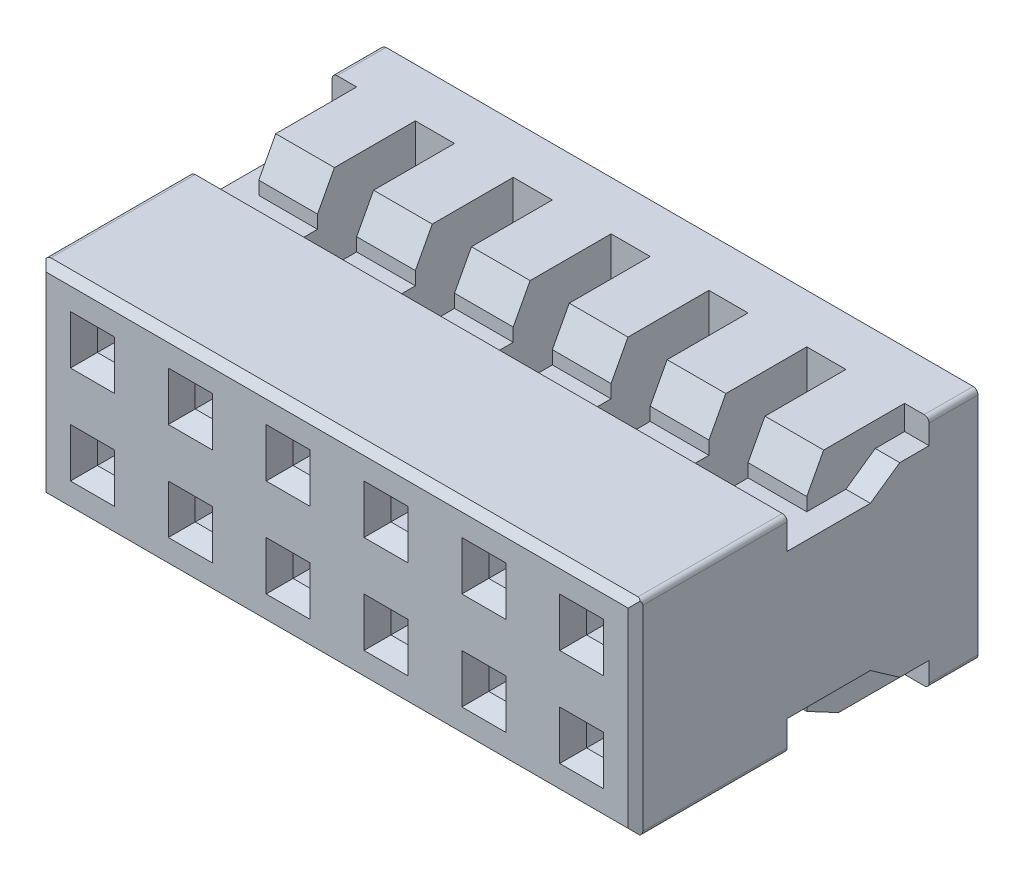
from build123d import *

# Parameters (mm, degrees)
SKETCH130_W                   = 7
SKETCH130_H                   = 4.8
EXTRUDE21_DEPTH               = 12.2
CUT_EXTRUDE110_DEPTH          = 0.5
CUT_EXTRUDE111_DEPTH          = 0.5
CUT_EXTRUDE112_DEPTH          = 0.5
CUT_EXTRUDE113_DEPTH          = 0.5
SKETCH135_W                   = 0.8
SKETCH135_H                   = 2.9
CUT_EXTRUDE114_DEPTH          = 4.8
SKETCH136_W                   = 0.8
SKETCH136_H                   = 2.9
CUT_EXTRUDE115_DEPTH          = 4.8
SKETCH137_W                   = 0.8
SKETCH137_H                   = 2.9
CUT_EXTRUDE116_DEPTH          = 4.8
SKETCH138_W                   = 0.8
SKETCH138_H                   = 2.9
CUT_EXTRUDE117_DEPTH          = 4.8
SKETCH139_W                   = 0.8
SKETCH139_H                   = 2.9
CUT_EXTRUDE118_DEPTH          = 4.8
SKETCH140_W                   = 1.2
SKETCH140_H                   = 0.920124523
CUT_EXTRUDE119_DEPTH          = 0.9
SKETCH141_W                   = 1.2
SKETCH141_H                   = 0.920124523
CUT_EXTRUDE120_DEPTH          = 0.9
SKETCH142_W                   = 1.2
SKETCH142_H                   = 0.920124523
CUT_EXTRUDE121_DEPTH          = 0.9
SKETCH143_W                   = 1.2
SKETCH143_H                   = 0.920124523
CUT_EXTRUDE122_DEPTH          = 0.9
SKETCH144_W                   = 0.8
SKETCH144_H                   = 2.959750954
CUT_EXTRUDE123_DEPTH          = 2.85
SKETCH145_W                   = 0.8
SKETCH145_H                   = 2.959750954
CUT_EXTRUDE124_DEPTH          = 2.85
SKETCH146_W                   = 0.8
SKETCH146_H                   = 2.959750954
CUT_EXTRUDE125_DEPTH          = 2.85
SKETCH147_W                   = 0.8
SKETCH147_H                   = 2.959750954
CUT_EXTRUDE126_DEPTH          = 2.85
SKETCH148_W                   = 0.8
SKETCH148_H                   = 2.959750954
CUT_EXTRUDE127_DEPTH          = 2.85
CUT_EXTRUDE128_DEPTH          = 0.3
CUT_EXTRUDE129_DEPTH          = 0.3
SKETCH151_W                   = 0.8
SKETCH151_H                   = 0.920124523
CUT_EXTRUDE130_DEPTH          = 1
SKETCH152_W                   = 0.8
SKETCH152_H                   = 0.920124523
CUT_EXTRUDE131_DEPTH          = 1
SKETCH153_W                   = 0.8
SKETCH153_H                   = 0.920124523
CUT_EXTRUDE132_DEPTH          = 1
SKETCH154_W                   = 0.8
SKETCH154_H                   = 0.920124523
CUT_EXTRUDE133_DEPTH          = 1
SKETCH155_W                   = 0.8
SKETCH155_H                   = 0.920124523
CUT_EXTRUDE134_DEPTH          = 1
SKETCH156_W                   = 0.8
SKETCH156_H                   = 1.840249046
EXTRUDE22_DEPTH               = 1.2
SKETCH157_W                   = 0.8
SKETCH157_H                   = 1.840249046
EXTRUDE23_DEPTH               = 1.2
SKETCH158_W                   = 0.8
SKETCH158_H                   = 1.840249046
EXTRUDE24_DEPTH               = 1.2
SKETCH159_W                   = 0.8
SKETCH159_H                   = 1.840249046
EXTRUDE25_DEPTH               = 1.2
SKETCH160_W                   = 0.8
SKETCH160_H                   = 1.840249046
EXTRUDE26_DEPTH               = 1.2
SKETCH161_W                   = 0.8
SKETCH161_H                   = 0.199377385
CUT_EXTRUDE135_DEPTH          = 1
LPATTERN13_COUNT              = 5
LPATTERN13_PITCH              = 2
SKETCH162_W                   = 1.2
SKETCH162_H                   = 0.9
CUT_EXTRUDE136_DEPTH          = 0.620124523
SKETCH163_W                   = 1.2
SKETCH163_H                   = 0.9
CUT_EXTRUDE137_DEPTH          = 0.620124523
SKETCH164_W                   = 1.2
SKETCH164_H                   = 0.9
CUT_EXTRUDE138_DEPTH          = 0.620124523
SKETCH165_W                   = 1.2
SKETCH165_H                   = 0.9
CUT_EXTRUDE139_DEPTH          = 0.620124523
SKETCH166_W                   = 1.2
SKETCH166_H                   = 0.9
CUT_EXTRUDE140_DEPTH          = 0.620124523
SKETCH167_W                   = 1.2
SKETCH167_H                   = 0.9
CUT_EXTRUDE141_DEPTH          = 0.620124523
SKETCH168_W                   = 1.2
SKETCH168_H                   = 0.9
CUT_EXTRUDE142_DEPTH          = 0.620124523
SKETCH169_W                   = 1.2
SKETCH169_H                   = 0.9
CUT_EXTRUDE143_DEPTH          = 0.620124523
CHAMFER85_SIZE                = 0.420124523
CHAMFER85_SIZE2               = 0.6
CHAMFER86_SIZE                = 0.420124523
CHAMFER86_SIZE2               = 0.6
CHAMFER87_SIZE                = 0.420124523
CHAMFER87_SIZE2               = 0.6
CHAMFER88_SIZE                = 0.420124523
CHAMFER88_SIZE2               = 0.6
CHAMFER89_SIZE                = 0.420124523
CHAMFER89_SIZE2               = 0.6
CHAMFER90_SIZE                = 0.6
CHAMFER90_SIZE2               = 0.420124523
CHAMFER91_SIZE                = 0.6
CHAMFER91_SIZE2               = 0.420124523
CHAMFER92_SIZE                = 0.6
CHAMFER92_SIZE2               = 0.420124523
CHAMFER93_SIZE                = 0.6
CHAMFER93_SIZE2               = 0.420124523
CHAMFER94_SIZE                = 0.6
CHAMFER94_SIZE2               = 0.420124523
CHAMFER95_SIZE                = 0.345611131
CHAMFER95_SIZE2               = 0.65
CHAMFER95_PART_2_SIZE         = 0.345611131
CHAMFER95_PART_2_SIZE2        = 0.65
CHAMFER95_PART_3_SIZE         = 0.345611131
CHAMFER95_PART_3_SIZE2        = 0.65
CHAMFER95_PART_4_SIZE         = 0.345611131
CHAMFER95_PART_4_SIZE2        = 0.65
CHAMFER95_PART_5_SIZE         = 0.345611131
CHAMFER95_PART_5_SIZE2        = 0.65
CHAMFER95_PART_6_SIZE         = 0.345611131
CHAMFER95_PART_6_SIZE2        = 0.65
CHAMFER96_SIZE                = 0.65
CHAMFER96_SIZE2               = 0.345611131
CHAMFER96_PART_2_SIZE         = 0.65
CHAMFER96_PART_2_SIZE2        = 0.345611131
CHAMFER96_PART_3_SIZE         = 0.65
CHAMFER96_PART_3_SIZE2        = 0.345611131
CHAMFER96_PART_4_SIZE         = 0.65
CHAMFER96_PART_4_SIZE2        = 0.345611131
CHAMFER96_PART_5_SIZE         = 0.65
CHAMFER96_PART_5_SIZE2        = 0.345611131
CHAMFER96_PART_6_SIZE         = 0.65
CHAMFER96_PART_6_SIZE2        = 0.345611131
SKETCH170_W                   = 0.5
SKETCH170_H                   = 0.6
CUT_EXTRUDE144_DEPTH          = 7
CHAMFER97_SIZE                = 0.2
CHAMFER97_SIZE2               = 0.35
CHAMFER98_SIZE                = 0.15
FILLET13_R                    = 0.1
FILLET14_R                    = 0.1
LPATTERN14_COUNT              = 6
LPATTERN14_PITCH              = 2
LPATTERN14_COUNT_DIR2         = 2
LPATTERN14_PITCH_DIR2         = 2
CHAMFER97_OF_LPATTERN14_SIZE2 = 0.35
CHAMFER97_OF_LPATTERN14_SIZE  = 0.2


with BuildPart() as part:
    # Sketch130 → Extrude21 (new body)
    with BuildSketch(Plane(origin=(6.1, 0, 0), x_dir=(0, 0, -1), z_dir=(1, 0, 0))):
        with Locations((3.5, 0)):
            Rectangle(SKETCH130_W, SKETCH130_H)
    extrude(amount=-EXTRUDE21_DEPTH)

    # Sketch131 → Cut-Extrude110 (cut)
    with BuildSketch(Plane(origin=(6.1, 0, 0), x_dir=(0, 0, -1), z_dir=(1, 0, 0))):
        Polygon((4.8, -1.479875477), (3.1, -1.479875477), (3.1, -2.4), (6, -2.4), (6, -1.9), (5.4, -1.9), align=None)
    extrude(amount=-CUT_EXTRUDE110_DEPTH, mode=Mode.SUBTRACT)

    # Sketch132 → Cut-Extrude111 (cut)
    with BuildSketch(Plane(origin=(6.1, 0, 0), x_dir=(0, 0, -1), z_dir=(1, 0, 0))):
        Polygon((6, 2.4), (3.1, 2.4), (3.1, 1.479875477), (4.8, 1.479875477), (5.4, 1.9), (6, 1.9), align=None)
    extrude(amount=-CUT_EXTRUDE111_DEPTH, mode=Mode.SUBTRACT)

    # Sketch133 → Cut-Extrude112 (cut)
    with BuildSketch(Plane.ZY.offset(6.1)):
        Polygon((-4.8, 1.479875477), (-3.1, 1.479875477), (-3.1, 2.4), (-6, 2.4), (-6, 1.9), (-5.4, 1.9), align=None)
    extrude(amount=-CUT_EXTRUDE112_DEPTH, mode=Mode.SUBTRACT)

    # Sketch134 → Cut-Extrude113 (cut)
    with BuildSketch(Plane.ZY.offset(6.1)):
        Polygon((-6, -2.4), (-3.1, -2.4), (-3.1, -1.479875477), (-4.8, -1.479875477), (-5.4, -1.9), (-6, -1.9), align=None)
    extrude(amount=-CUT_EXTRUDE113_DEPTH, mode=Mode.SUBTRACT)

    # Sketch135 → Cut-Extrude114 (cut)
    with BuildSketch(Plane(origin=(0, 2.4, 0), x_dir=(-1, 0, 0), z_dir=(0, 1, 0))):
        with Locations((-4, -4.55)):
            Rectangle(SKETCH135_W, SKETCH135_H)
    extrude(amount=-CUT_EXTRUDE114_DEPTH, mode=Mode.SUBTRACT)

    # Sketch136 → Cut-Extrude115 (cut)
    with BuildSketch(Plane(origin=(0, 2.4, 0), x_dir=(-1, 0, 0), z_dir=(0, 1, 0))):
        with Locations((-2, -4.55)):
            Rectangle(SKETCH136_W, SKETCH136_H)
    extrude(amount=-CUT_EXTRUDE115_DEPTH, mode=Mode.SUBTRACT)

    # Sketch137 → Cut-Extrude116 (cut)
    with BuildSketch(Plane(origin=(0, 2.4, 0), x_dir=(-1, 0, 0), z_dir=(0, 1, 0))):
        with Locations((0, -4.55)):
            Rectangle(SKETCH137_W, SKETCH137_H)
    extrude(amount=-CUT_EXTRUDE116_DEPTH, mode=Mode.SUBTRACT)

    # Sketch138 → Cut-Extrude117 (cut)
    with BuildSketch(Plane(origin=(0, 2.4, 0), x_dir=(-1, 0, 0), z_dir=(0, 1, 0))):
        with Locations((2, -4.55)):
            Rectangle(SKETCH138_W, SKETCH138_H)
    extrude(amount=-CUT_EXTRUDE117_DEPTH, mode=Mode.SUBTRACT)

    # Sketch139 → Cut-Extrude118 (cut)
    with BuildSketch(Plane(origin=(0, 2.4, 0), x_dir=(-1, 0, 0), z_dir=(0, 1, 0))):
        with Locations((4, -4.55)):
            Rectangle(SKETCH139_W, SKETCH139_H)
    extrude(amount=-CUT_EXTRUDE118_DEPTH, mode=Mode.SUBTRACT)

    # Sketch140 → Cut-Extrude119 (cut)
    with BuildSketch(Plane.XY.offset(-3.1)):
        with Locations((5, -1.939937739)):
            Rectangle(SKETCH140_W, SKETCH140_H)
    extrude(amount=-CUT_EXTRUDE119_DEPTH, mode=Mode.SUBTRACT)

    # Sketch141 → Cut-Extrude120 (cut)
    with BuildSketch(Plane.XY.offset(-3.1)):
        with Locations((-5, -1.939937739)):
            Rectangle(SKETCH141_W, SKETCH141_H)
    extrude(amount=-CUT_EXTRUDE120_DEPTH, mode=Mode.SUBTRACT)

    # Sketch142 → Cut-Extrude121 (cut)
    with BuildSketch(Plane.XY.offset(-3.1)):
        with Locations((5, 1.939937739)):
            Rectangle(SKETCH142_W, SKETCH142_H)
    extrude(amount=-CUT_EXTRUDE121_DEPTH, mode=Mode.SUBTRACT)

    # Sketch143 → Cut-Extrude122 (cut)
    with BuildSketch(Plane.XY.offset(-3.1)):
        with Locations((-5, 1.939937739)):
            Rectangle(SKETCH143_W, SKETCH143_H)
    extrude(amount=-CUT_EXTRUDE122_DEPTH, mode=Mode.SUBTRACT)

    # Sketch144 → Cut-Extrude123 (cut)
    with BuildSketch(Plane(origin=(0, 0, -3.1), x_dir=(-1, 0, 0), z_dir=(0, 0, -1))):
        with Locations((-4, 0)):
            Rectangle(SKETCH144_W, SKETCH144_H)
    extrude(amount=-CUT_EXTRUDE123_DEPTH, mode=Mode.SUBTRACT)

    # Sketch145 → Cut-Extrude124 (cut)
    with BuildSketch(Plane(origin=(0, 0, -3.1), x_dir=(-1, 0, 0), z_dir=(0, 0, -1))):
        with Locations((-2, 0)):
            Rectangle(SKETCH145_W, SKETCH145_H)
    extrude(amount=-CUT_EXTRUDE124_DEPTH, mode=Mode.SUBTRACT)

    # Sketch146 → Cut-Extrude125 (cut)
    with BuildSketch(Plane(origin=(0, 0, -3.1), x_dir=(-1, 0, 0), z_dir=(0, 0, -1))):
        Rectangle(SKETCH146_W, SKETCH146_H)
    extrude(amount=-CUT_EXTRUDE125_DEPTH, mode=Mode.SUBTRACT)

    # Sketch147 → Cut-Extrude126 (cut)
    with BuildSketch(Plane(origin=(0, 0, -3.1), x_dir=(-1, 0, 0), z_dir=(0, 0, -1))):
        with Locations((2, 0)):
            Rectangle(SKETCH147_W, SKETCH147_H)
    extrude(amount=-CUT_EXTRUDE126_DEPTH, mode=Mode.SUBTRACT)

    # Sketch148 → Cut-Extrude127 (cut)
    with BuildSketch(Plane(origin=(0, 0, -3.1), x_dir=(-1, 0, 0), z_dir=(0, 0, -1))):
        with Locations((4, 0)):
            Rectangle(SKETCH148_W, SKETCH148_H)
    extrude(amount=-CUT_EXTRUDE127_DEPTH, mode=Mode.SUBTRACT)

    # Sketch149 → Cut-Extrude128 (cut)
    with BuildSketch(Plane.XZ.offset(2.4)):
        Polygon((6.1, -3.1), (6.1, 0), (-6.1, 0), (-6.1, -3.1), (-3.6, -3.1), (-3.6, -4), (-2.4, -4), (-2.4, -3.1), (-1.6, -3.1), (-1.6, -4), (-0.4, -4), (-0.4, -3.1), (0.4, -3.1), (0.4, -4), (1.6, -4), (1.6, -3.1), (2.4, -3.1), (2.4, -4), (3.6, -4), (3.6, -3.1), align=None)
    extrude(amount=-CUT_EXTRUDE128_DEPTH, mode=Mode.SUBTRACT)

    # Sketch150 → Cut-Extrude129 (cut)
    with BuildSketch(Plane(origin=(0, 2.4, 0), x_dir=(-1, 0, 0), z_dir=(0, 1, 0))):
        Polygon((3.6, -3.1), (6.1, -3.1), (6.1, 0), (-6.1, 0), (-6.1, -3.1), (-3.6, -3.1), (-3.6, -4), (-2.4, -4), (-2.4, -3.1), (-1.6, -3.1), (-1.6, -4), (-0.4, -4), (-0.4, -3.1), (0.4, -3.1), (0.4, -4), (1.6, -4), (1.6, -3.1), (2.4, -3.1), (2.4, -4), (3.6, -4), align=None)
    extrude(amount=-CUT_EXTRUDE129_DEPTH, mode=Mode.SUBTRACT)

    # Sketch151 → Cut-Extrude130 (cut)
    with BuildSketch(Plane.XY.offset(-6)):
        with Locations((-4, 1.019813216)):
            Rectangle(SKETCH151_W, SKETCH151_H)
    extrude(amount=-CUT_EXTRUDE130_DEPTH, mode=Mode.SUBTRACT)

    # Sketch152 → Cut-Extrude131 (cut)
    with BuildSketch(Plane.XY.offset(-6)):
        with Locations((-2, 1.019813216)):
            Rectangle(SKETCH152_W, SKETCH152_H)
    extrude(amount=-CUT_EXTRUDE131_DEPTH, mode=Mode.SUBTRACT)

    # Sketch153 → Cut-Extrude132 (cut)
    with BuildSketch(Plane.XY.offset(-6)):
        with Locations((0, 1.019813216)):
            Rectangle(SKETCH153_W, SKETCH153_H)
    extrude(amount=-CUT_EXTRUDE132_DEPTH, mode=Mode.SUBTRACT)

    # Sketch154 → Cut-Extrude133 (cut)
    with BuildSketch(Plane.XY.offset(-6)):
        with Locations((2, 1.019813216)):
            Rectangle(SKETCH154_W, SKETCH154_H)
    extrude(amount=-CUT_EXTRUDE133_DEPTH, mode=Mode.SUBTRACT)

    # Sketch155 → Cut-Extrude134 (cut)
    with BuildSketch(Plane.XY.offset(-6)):
        with Locations((4, 1.019813216)):
            Rectangle(SKETCH155_W, SKETCH155_H)
    extrude(amount=-CUT_EXTRUDE134_DEPTH, mode=Mode.SUBTRACT)

    # Sketch156 → Extrude22 (add)
    with BuildSketch(Plane.XY.offset(-6)):
        with Locations((-4, -0.360373569)):
            Rectangle(SKETCH156_W, SKETCH156_H)
    extrude(amount=EXTRUDE22_DEPTH)

    # Sketch157 → Extrude23 (add)
    with BuildSketch(Plane.XY.offset(-6)):
        with Locations((-2, -0.360373569)):
            Rectangle(SKETCH157_W, SKETCH157_H)
    extrude(amount=EXTRUDE23_DEPTH)

    # Sketch158 → Extrude24 (add)
    with BuildSketch(Plane.XY.offset(-6)):
        with Locations((0, -0.360373569)):
            Rectangle(SKETCH158_W, SKETCH158_H)
    extrude(amount=EXTRUDE24_DEPTH)

    # Sketch159 → Extrude25 (add)
    with BuildSketch(Plane.XY.offset(-6)):
        with Locations((2, -0.360373569)):
            Rectangle(SKETCH159_W, SKETCH159_H)
    extrude(amount=EXTRUDE25_DEPTH)

    # Sketch160 → Extrude26 (add)
    with BuildSketch(Plane.XY.offset(-6)):
        with Locations((4, -0.360373569)):
            Rectangle(SKETCH160_W, SKETCH160_H)
    extrude(amount=EXTRUDE26_DEPTH)

    # Sketch161 → Cut-Extrude135 (cut)
    with BuildSketch(Plane.XY.offset(-6)):
        with Locations((-4, -1.380186784)):
            Rectangle(SKETCH161_W, SKETCH161_H)
    cut_extrude135 = extrude(amount=-CUT_EXTRUDE135_DEPTH, mode=Mode.SUBTRACT)

    # LPattern13: Cut-Extrude135 ×5
    with Locations(*[(i * LPATTERN13_PITCH, 0, 0) for i in range(1, LPATTERN13_COUNT)]):
        add(cut_extrude135, mode=Mode.SUBTRACT)

    # Sketch162 → Cut-Extrude136 (cut)
    with BuildSketch(Plane.XZ.offset(2.1)):
        with Locations((-3, -3.55)):
            Rectangle(SKETCH162_W, SKETCH162_H)
    extrude(amount=-CUT_EXTRUDE136_DEPTH, mode=Mode.SUBTRACT)

    # Sketch163 → Cut-Extrude137 (cut)
    with BuildSketch(Plane.XZ.offset(2.1)):
        with Locations((-1, -3.55)):
            Rectangle(SKETCH163_W, SKETCH163_H)
    extrude(amount=-CUT_EXTRUDE137_DEPTH, mode=Mode.SUBTRACT)

    # Sketch164 → Cut-Extrude138 (cut)
    with BuildSketch(Plane.XZ.offset(2.1)):
        with Locations((1, -3.55)):
            Rectangle(SKETCH164_W, SKETCH164_H)
    extrude(amount=-CUT_EXTRUDE138_DEPTH, mode=Mode.SUBTRACT)

    # Sketch165 → Cut-Extrude139 (cut)
    with BuildSketch(Plane.XZ.offset(2.1)):
        with Locations((3, -3.55)):
            Rectangle(SKETCH165_W, SKETCH165_H)
    extrude(amount=-CUT_EXTRUDE139_DEPTH, mode=Mode.SUBTRACT)

    # Sketch166 → Cut-Extrude140 (cut)
    with BuildSketch(Plane(origin=(0, 2.1, 0), x_dir=(-1, 0, 0), z_dir=(0, 1, 0))):
        with Locations((-3, -3.55)):
            Rectangle(SKETCH166_W, SKETCH166_H)
    extrude(amount=-CUT_EXTRUDE140_DEPTH, mode=Mode.SUBTRACT)

    # Sketch167 → Cut-Extrude141 (cut)
    with BuildSketch(Plane(origin=(0, 2.1, 0), x_dir=(-1, 0, 0), z_dir=(0, 1, 0))):
        with Locations((-1, -3.55)):
            Rectangle(SKETCH167_W, SKETCH167_H)
    extrude(amount=-CUT_EXTRUDE141_DEPTH, mode=Mode.SUBTRACT)

    # Sketch168 → Cut-Extrude142 (cut)
    with BuildSketch(Plane(origin=(0, 2.1, 0), x_dir=(-1, 0, 0), z_dir=(0, 1, 0))):
        with Locations((1, -3.55)):
            Rectangle(SKETCH168_W, SKETCH168_H)
    extrude(amount=-CUT_EXTRUDE142_DEPTH, mode=Mode.SUBTRACT)

    # Sketch169 → Cut-Extrude143 (cut)
    with BuildSketch(Plane(origin=(0, 2.1, 0), x_dir=(-1, 0, 0), z_dir=(0, 1, 0))):
        with Locations((3, -3.55)):
            Rectangle(SKETCH169_W, SKETCH169_H)
    extrude(amount=-CUT_EXTRUDE143_DEPTH, mode=Mode.SUBTRACT)

    # Chamfer85
    chamfer85_edges = [part.edges().sort_by_distance(p)[0] for p in [
        (4, -1.280498092, -4.8),
    ]]
    chamfer85_side = [part.faces().sort_by_distance(p)[0] for p in [
        (4, -1.280498092, -5.9),
    ]]
    chamfer(chamfer85_edges, length=CHAMFER85_SIZE, length2=CHAMFER85_SIZE2, reference=chamfer85_side[0])

    # Chamfer86
    chamfer86_edges = [part.edges().sort_by_distance(p)[0] for p in [
        (2, -1.280498092, -4.8),
    ]]
    chamfer86_side = [part.faces().sort_by_distance(p)[0] for p in [
        (2, -1.280498092, -5.9),
    ]]
    chamfer(chamfer86_edges, length=CHAMFER86_SIZE, length2=CHAMFER86_SIZE2, reference=chamfer86_side[0])

    # Chamfer87
    chamfer87_edges = [part.edges().sort_by_distance(p)[0] for p in [
        (0, -1.280498092, -4.8),
    ]]
    chamfer87_side = [part.faces().sort_by_distance(p)[0] for p in [
        (0, -1.280498092, -5.9),
    ]]
    chamfer(chamfer87_edges, length=CHAMFER87_SIZE, length2=CHAMFER87_SIZE2, reference=chamfer87_side[0])

    # Chamfer88
    chamfer88_edges = [part.edges().sort_by_distance(p)[0] for p in [
        (-2, -1.280498092, -4.8),
    ]]
    chamfer88_side = [part.faces().sort_by_distance(p)[0] for p in [
        (-2, -1.280498092, -5.9),
    ]]
    chamfer(chamfer88_edges, length=CHAMFER88_SIZE, length2=CHAMFER88_SIZE2, reference=chamfer88_side[0])

    # Chamfer89
    chamfer89_edges = [part.edges().sort_by_distance(p)[0] for p in [
        (-4, -1.280498092, -4.8),
    ]]
    chamfer89_side = [part.faces().sort_by_distance(p)[0] for p in [
        (-4, -1.280498092, -5.9),
    ]]
    chamfer(chamfer89_edges, length=CHAMFER89_SIZE, length2=CHAMFER89_SIZE2, reference=chamfer89_side[0])

    # Chamfer90
    chamfer90_edges = [part.edges().sort_by_distance(p)[0] for p in [
        (4, 0.559750954, -4.8),
    ]]
    chamfer90_side = [part.faces().sort_by_distance(p)[0] for p in [
        (4, 0.559750954, -5.9),
    ]]
    chamfer(chamfer90_edges, length=CHAMFER90_SIZE, length2=CHAMFER90_SIZE2, reference=chamfer90_side[0])

    # Chamfer91
    chamfer91_edges = [part.edges().sort_by_distance(p)[0] for p in [
        (2, 0.559750954, -4.8),
    ]]
    chamfer91_side = [part.faces().sort_by_distance(p)[0] for p in [
        (2, 0.559750954, -5.9),
    ]]
    chamfer(chamfer91_edges, length=CHAMFER91_SIZE, length2=CHAMFER91_SIZE2, reference=chamfer91_side[0])

    # Chamfer92
    chamfer92_edges = [part.edges().sort_by_distance(p)[0] for p in [
        (0, 0.559750954, -4.8),
    ]]
    chamfer92_side = [part.faces().sort_by_distance(p)[0] for p in [
        (0, 0.559750954, -5.9),
    ]]
    chamfer(chamfer92_edges, length=CHAMFER92_SIZE, length2=CHAMFER92_SIZE2, reference=chamfer92_side[0])

    # Chamfer93
    chamfer93_edges = [part.edges().sort_by_distance(p)[0] for p in [
        (-2, 0.559750954, -4.8),
    ]]
    chamfer93_side = [part.faces().sort_by_distance(p)[0] for p in [
        (-2, 0.559750954, -5.9),
    ]]
    chamfer(chamfer93_edges, length=CHAMFER93_SIZE, length2=CHAMFER93_SIZE2, reference=chamfer93_side[0])

    # Chamfer94
    chamfer94_edges = [part.edges().sort_by_distance(p)[0] for p in [
        (-4, 0.559750954, -4.8),
    ]]
    chamfer94_side = [part.faces().sort_by_distance(p)[0] for p in [
        (-4, 0.559750954, -5.9),
    ]]
    chamfer(chamfer94_edges, length=CHAMFER94_SIZE, length2=CHAMFER94_SIZE2, reference=chamfer94_side[0])

    # Chamfer95
    chamfer95_edges = [part.edges().sort_by_distance(p)[0] for p in [
        (5, -2.4, -4),
    ]]
    chamfer95_side = [part.faces().sort_by_distance(p)[0] for p in [
        (5, -1.939937739, -4),
    ]]
    chamfer(chamfer95_edges, length=CHAMFER95_SIZE, length2=CHAMFER95_SIZE2, reference=chamfer95_side[0])

    # Chamfer95 part 2
    chamfer95_part_2_edges = [part.edges().sort_by_distance(p)[0] for p in [
        (-5, -2.4, -4),
    ]]
    chamfer95_part_2_side = [part.faces().sort_by_distance(p)[0] for p in [
        (-5, -1.939937739, -4),
    ]]
    chamfer(chamfer95_part_2_edges, length=CHAMFER95_PART_2_SIZE, length2=CHAMFER95_PART_2_SIZE2, reference=chamfer95_part_2_side[0])

    # Chamfer95 part 3
    chamfer95_part_3_edges = [part.edges().sort_by_distance(p)[0] for p in [
        (-3, -2.4, -4),
    ]]
    chamfer95_part_3_side = [part.faces().sort_by_distance(p)[0] for p in [
        (-3, -1.939937739, -4),
    ]]
    chamfer(chamfer95_part_3_edges, length=CHAMFER95_PART_3_SIZE, length2=CHAMFER95_PART_3_SIZE2, reference=chamfer95_part_3_side[0])

    # Chamfer95 part 4
    chamfer95_part_4_edges = [part.edges().sort_by_distance(p)[0] for p in [
        (-1, -2.4, -4),
    ]]
    chamfer95_part_4_side = [part.faces().sort_by_distance(p)[0] for p in [
        (-1, -1.939937739, -4),
    ]]
    chamfer(chamfer95_part_4_edges, length=CHAMFER95_PART_4_SIZE, length2=CHAMFER95_PART_4_SIZE2, reference=chamfer95_part_4_side[0])

    # Chamfer95 part 5
    chamfer95_part_5_edges = [part.edges().sort_by_distance(p)[0] for p in [
        (1, -2.4, -4),
    ]]
    chamfer95_part_5_side = [part.faces().sort_by_distance(p)[0] for p in [
        (1, -1.939937739, -4),
    ]]
    chamfer(chamfer95_part_5_edges, length=CHAMFER95_PART_5_SIZE, length2=CHAMFER95_PART_5_SIZE2, reference=chamfer95_part_5_side[0])

    # Chamfer95 part 6
    chamfer95_part_6_edges = [part.edges().sort_by_distance(p)[0] for p in [
        (3, -2.4, -4),
    ]]
    chamfer95_part_6_side = [part.faces().sort_by_distance(p)[0] for p in [
        (3, -1.939937739, -4),
    ]]
    chamfer(chamfer95_part_6_edges, length=CHAMFER95_PART_6_SIZE, length2=CHAMFER95_PART_6_SIZE2, reference=chamfer95_part_6_side[0])

    # Chamfer96
    chamfer96_edges = [part.edges().sort_by_distance(p)[0] for p in [
        (5, 2.4, -4),
    ]]
    chamfer96_side = [part.faces().sort_by_distance(p)[0] for p in [
        (5, 1.939937739, -4),
    ]]
    chamfer(chamfer96_edges, length=CHAMFER96_SIZE, length2=CHAMFER96_SIZE2, reference=chamfer96_side[0])

    # Chamfer96 part 2
    chamfer96_part_2_edges = [part.edges().sort_by_distance(p)[0] for p in [
        (-5, 2.4, -4),
    ]]
    chamfer96_part_2_side = [part.faces().sort_by_distance(p)[0] for p in [
        (-5, 1.939937739, -4),
    ]]
    chamfer(chamfer96_part_2_edges, length=CHAMFER96_PART_2_SIZE, length2=CHAMFER96_PART_2_SIZE2, reference=chamfer96_part_2_side[0])

    # Chamfer96 part 3
    chamfer96_part_3_edges = [part.edges().sort_by_distance(p)[0] for p in [
        (3, 2.4, -4),
    ]]
    chamfer96_part_3_side = [part.faces().sort_by_distance(p)[0] for p in [
        (3, 1.939937739, -4),
    ]]
    chamfer(chamfer96_part_3_edges, length=CHAMFER96_PART_3_SIZE, length2=CHAMFER96_PART_3_SIZE2, reference=chamfer96_part_3_side[0])

    # Chamfer96 part 4
    chamfer96_part_4_edges = [part.edges().sort_by_distance(p)[0] for p in [
        (1, 2.4, -4),
    ]]
    chamfer96_part_4_side = [part.faces().sort_by_distance(p)[0] for p in [
        (1, 1.939937739, -4),
    ]]
    chamfer(chamfer96_part_4_edges, length=CHAMFER96_PART_4_SIZE, length2=CHAMFER96_PART_4_SIZE2, reference=chamfer96_part_4_side[0])

    # Chamfer96 part 5
    chamfer96_part_5_edges = [part.edges().sort_by_distance(p)[0] for p in [
        (-1, 2.4, -4),
    ]]
    chamfer96_part_5_side = [part.faces().sort_by_distance(p)[0] for p in [
        (-1, 1.939937739, -4),
    ]]
    chamfer(chamfer96_part_5_edges, length=CHAMFER96_PART_5_SIZE, length2=CHAMFER96_PART_5_SIZE2, reference=chamfer96_part_5_side[0])

    # Chamfer96 part 6
    chamfer96_part_6_edges = [part.edges().sort_by_distance(p)[0] for p in [
        (-3, 2.4, -4),
    ]]
    chamfer96_part_6_side = [part.faces().sort_by_distance(p)[0] for p in [
        (-3, 1.939937739, -4),
    ]]
    chamfer(chamfer96_part_6_edges, length=CHAMFER96_PART_6_SIZE, length2=CHAMFER96_PART_6_SIZE2, reference=chamfer96_part_6_side[0])

    # Sketch170 → Cut-Extrude144 (cut)
    with BuildSketch(Plane.XY):
        with Locations((5, 1)):
            Rectangle(SKETCH170_W, SKETCH170_H)
    cut_extrude144 = extrude(amount=-CUT_EXTRUDE144_DEPTH, mode=Mode.SUBTRACT)

    # Chamfer97
    chamfer97_edges = [part.edges().sort_by_distance(p)[0] for p in [
        (4.75, 1, 0),
        (5, 0.7, 0),
        (5.25, 1, 0),
        (5, 1.3, 0),
    ]]
    chamfer97_side = [part.faces().sort_by_distance(p)[0] for p in [
        (-0.029446408, -0.005889282, 0),
    ]]
    chamfer(chamfer97_edges, length=CHAMFER97_SIZE, length2=CHAMFER97_SIZE2, reference=chamfer97_side[0])

    # Chamfer98
    chamfer98_edges = [part.edges().sort_by_distance(p)[0] for p in [
        (0, -2.1, 0),
        (6.1, 0, 0),
        (-6.1, 0, 0),
        (0, 2.1, 0),
    ]]
    chamfer(chamfer98_edges, length=CHAMFER98_SIZE)

    # Fillet13
    fillet13_edges = [part.edges().sort_by_distance(p)[0] for p in [
        (6.1, -2.4, -6.5),
        (-6.1, 2.4, -6.5),
        (6.1, 2.4, -6.5),
        (-6.1, -2.4, -6.5),
    ]]
    fillet(fillet13_edges, radius=FILLET13_R)

    # Fillet14
    fillet14_edges = [part.edges().sort_by_distance(p)[0] for p in [
        (6.1, -2.1, -1.625),
        (-6.1, 2.1, -1.625),
        (-6.1, -2.1, -1.625),
        (6.1, 2.1, -1.625),
    ]]
    fillet(fillet14_edges, radius=FILLET14_R)

    # LPattern14: Cut-Extrude144 6 × 2
    with Locations(*[(-i * LPATTERN14_PITCH, -j * LPATTERN14_PITCH_DIR2, 0) for i in range(LPATTERN14_COUNT) for j in range(LPATTERN14_COUNT_DIR2) if (i, j) != (0, 0)]):
        add(cut_extrude144, mode=Mode.SUBTRACT)

    # Chamfer97 of LPattern14
    chamfer97_of_lpattern14_edges = [part.edges().sort_by_distance(p)[0] for p in [
        (4.75, -1, 0),
        (5, -1.3, 0),
        (5.25, -1, 0),
        (5, -0.7, 0),
        (2.75, 1, 0),
        (3, 0.7, 0),
        (3.25, 1, 0),
        (3, 1.3, 0),
        (2.75, -1, 0),
        (3, -1.3, 0),
        (3.25, -1, 0),
        (3, -0.7, 0),
        (0.75, 1, 0),
        (1, 0.7, 0),
        (1.25, 1, 0),
        (1, 1.3, 0),
        (0.75, -1, 0),
        (1, -1.3, 0),
        (1.25, -1, 0),
        (1, -0.7, 0),
        (-1.25, 1, 0),
        (-1, 0.7, 0),
        (-0.75, 1, 0),
        (-1, 1.3, 0),
        (-1.25, -1, 0),
        (-1, -1.3, 0),
        (-0.75, -1, 0),
        (-1, -0.7, 0),
        (-3.25, 1, 0),
        (-3, 0.7, 0),
        (-2.75, 1, 0),
        (-3, 1.3, 0),
        (-3.25, -1, 0),
        (-3, -1.3, 0),
        (-2.75, -1, 0),
        (-3, -0.7, 0),
        (-5.25, 1, 0),
        (-5, 0.7, 0),
        (-4.75, 1, 0),
        (-5, 1.3, 0),
        (-5.25, -1, 0),
        (-5, -1.3, 0),
        (-4.75, -1, 0),
        (-5, -0.7, 0),
    ]]
    chamfer(chamfer97_of_lpattern14_edges, length=CHAMFER97_OF_LPATTERN14_SIZE, length2=CHAMFER97_OF_LPATTERN14_SIZE2)


solid = part.part
